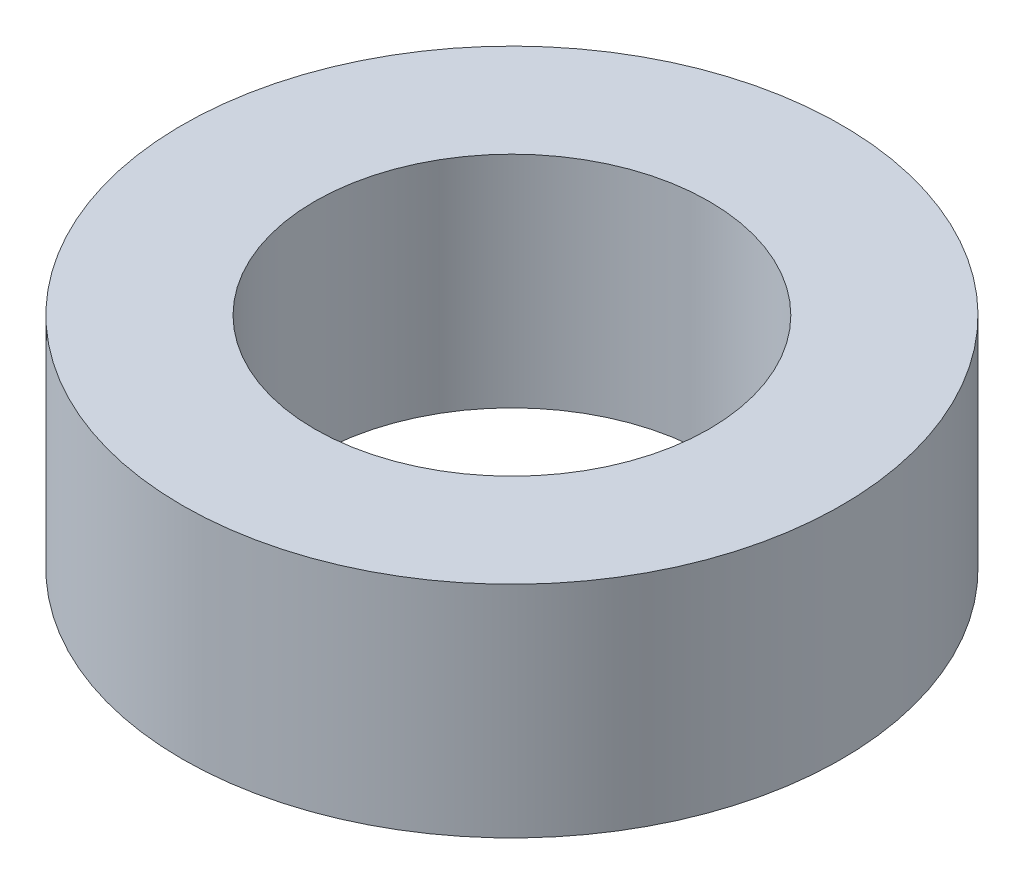
from build123d import *

# Parameters (mm, degrees)
SKETCH1_R      = 4.7625
SKETCH1_R_2    = 2.850007
EXTRUDE1_DEPTH = 3.175


with BuildPart() as part:
    # Sketch1 → Extrude1 (new body)
    with BuildSketch(Plane(origin=(0, 0, 0), x_dir=(1, 0, 0), z_dir=(0, 1, 0))):
        with Locations(Location((0, 0, 0), (0, 0, 270))):  # turned: the seam where the file's is
            Circle(SKETCH1_R)
        with Locations(Location((0, 0, 0), (0, 0, 270))):  # turned: the seam where the file's is
            Circle(SKETCH1_R_2, mode=Mode.SUBTRACT)
    extrude(amount=EXTRUDE1_DEPTH)


solid = part.part
